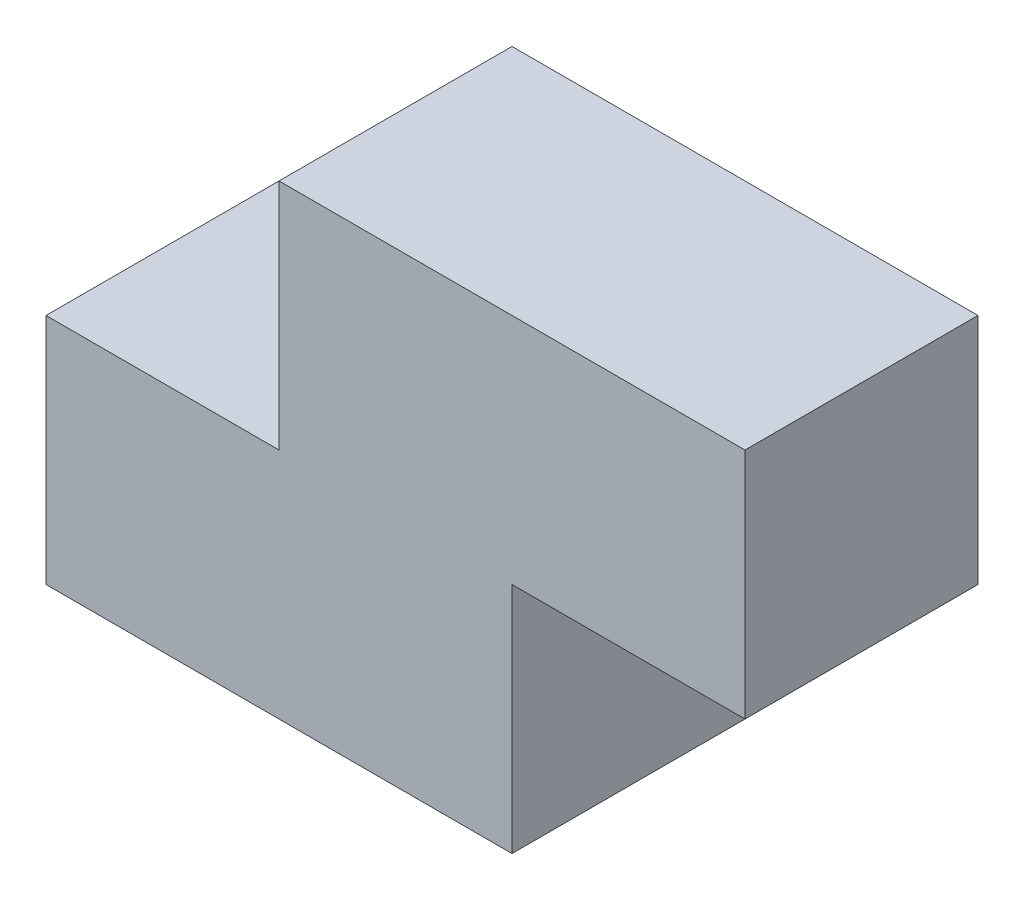
from build123d import *

# Parameters (mm, degrees)
BOSS_EXTRU_1_DEPTH = 30


with BuildPart() as part:
    # Esquisse1 → Boss.-Extru.1 (new body)
    with BuildSketch(Plane.XY):
        Polygon((0, 0), (60, 0), (60, 30), (90, 30), (90, 60), (30, 60), (30, 30), (0, 30), align=None)
    extrude(amount=BOSS_EXTRU_1_DEPTH)


solid = part.part
